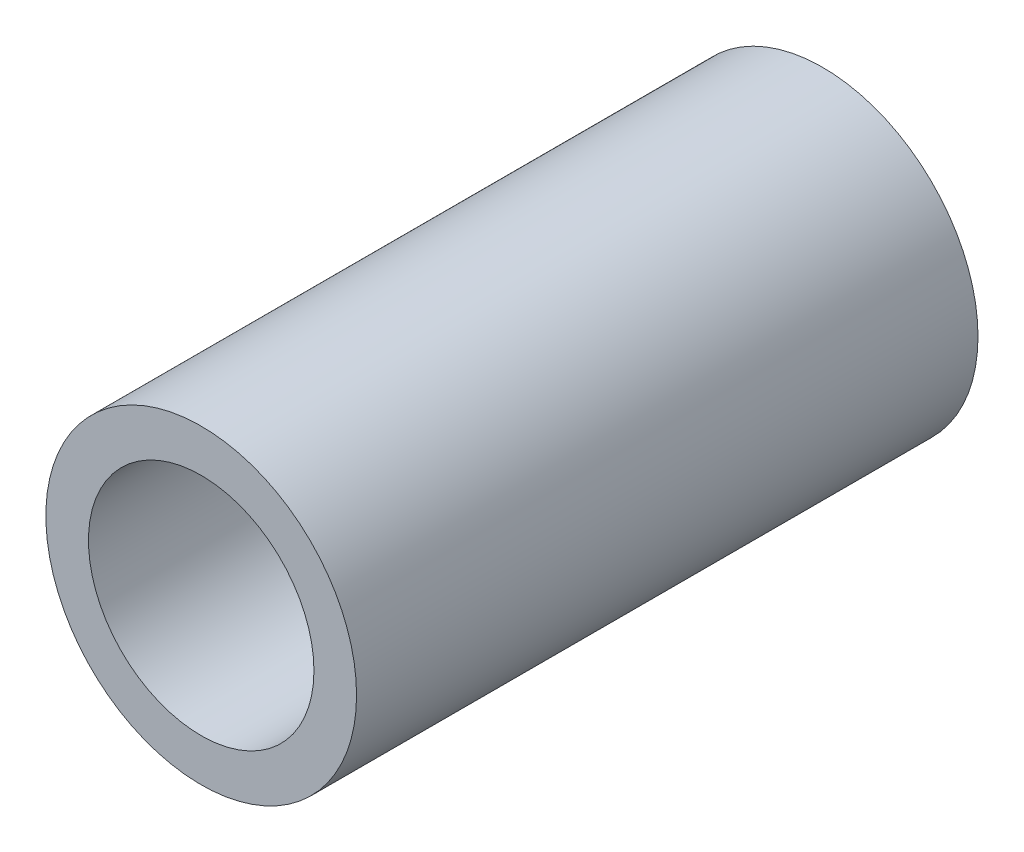
from build123d import *

# Parameters (mm, degrees)
SKETCH1_R      = 11.1125
SKETCH1_R_2    = 8.0645
EXTRUDE1_DEPTH = 22.225


with BuildPart() as part:
    # Sketch1 → Extrude1 (new body, symmetric)
    with BuildSketch(Plane.XY):
        Circle(SKETCH1_R)
        Circle(SKETCH1_R_2, mode=Mode.SUBTRACT)
    extrude(amount=EXTRUDE1_DEPTH, both=True)


solid = part.part
